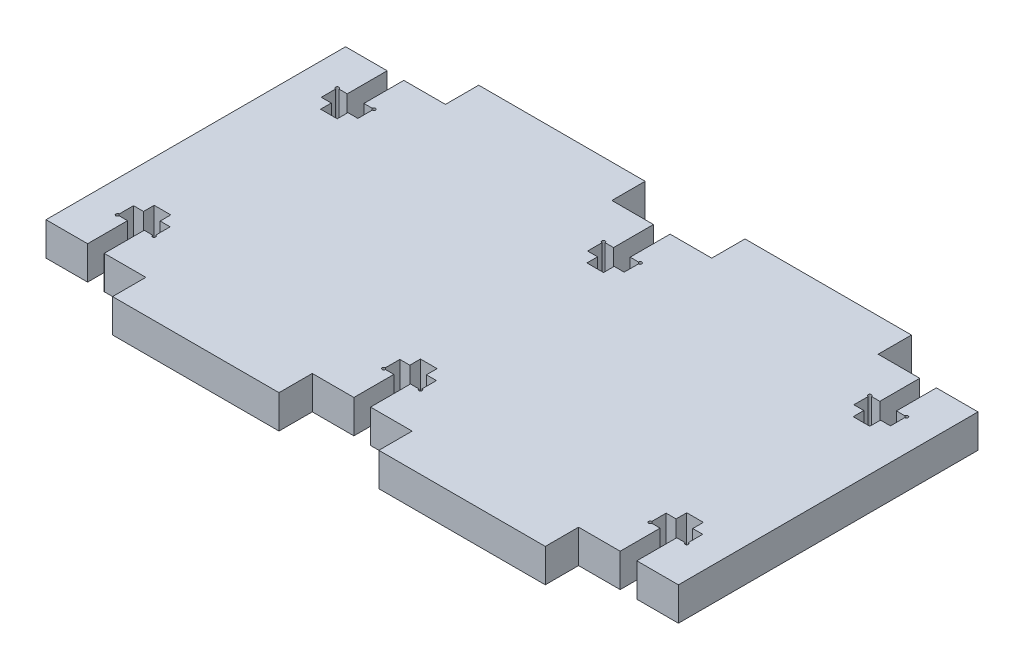
from build123d import *

# Parameters (mm, degrees)
SCHIZZO1_W                   = 95
SCHIZZO1_H                   = 55
ESTRUSIONE_ESTRUSIONE2_DEPTH = 5
SCHIZZO2_W                   = 15
SCHIZZO2_H                   = 5
TAGLIO_ESTRUSIONE1_DEPTH     = 6
TAGLIO_ESTRUSIONE3_DEPTH     = 6
SCHIZZO4_R                   = 0.25
TAGLIO_ESTRUSIONE4_DEPTH     = 10


with BuildPart() as part:
    # Schizzo1 → Estrusione-Estrusione2 (new body)
    with BuildSketch(Plane(origin=(0, 0, 0), x_dir=(1, 0, 0), z_dir=(0, 1, 0))):
        with Locations((-7.06494914, -0.781075862)):
            Rectangle(SCHIZZO1_W, SCHIZZO1_H)
    extrude(amount=-ESTRUSIONE_ESTRUSIONE2_DEPTH)

    # Schizzo2 → Taglio-Estrusione1 (cut, through all)
    with BuildSketch(Plane(origin=(0, 0, 0), x_dir=(1, 0, 0), z_dir=(0, 1, 0))):
        with Locations((-47.06494914, -25.781075862)):
            Rectangle(SCHIZZO2_W, SCHIZZO2_H)
        with Locations((-47.06494914, 24.218924138)):
            Rectangle(SCHIZZO2_W, SCHIZZO2_H)
        with Locations((32.93505086, -25.781075862)):
            Rectangle(SCHIZZO2_W, SCHIZZO2_H)
        with Locations((32.93505086, 24.218924138)):
            Rectangle(SCHIZZO2_W, SCHIZZO2_H)
        with Locations((-7.06494914, -25.781075862)):
            Rectangle(SCHIZZO2_W, SCHIZZO2_H)
        with Locations((-7.06494914, 24.218924138)):
            Rectangle(SCHIZZO2_W, SCHIZZO2_H)
    extrude(amount=-TAGLIO_ESTRUSIONE1_DEPTH, mode=Mode.SUBTRACT)

    # Schizzo3 → Taglio-Estrusione3 (cut, through all)
    with BuildSketch(Plane(origin=(0, 0, 0), x_dir=(1, 0, 0), z_dir=(0, 1, 0))):
        Polygon((-48.31494914, -23.281075862), (-45.81494914, -23.281075862), (-45.81494914, -17.281075862), (-44.31494914, -17.281075862), (-44.31494914, -14.881075862), (-45.81494914, -14.881075862), (-45.81494914, -13.281075862), (-48.31494914, -13.281075862), (-48.31494914, -14.881075862), (-49.81494914, -14.881075862), (-49.81494914, -17.281075862), (-48.31494914, -17.281075862), align=None)
        Polygon((-8.31494914, -23.281075862), (-5.81494914, -23.281075862), (-5.81494914, -17.281075862), (-4.31494914, -17.281075862), (-4.31494914, -14.881075862), (-5.81494914, -14.881075862), (-5.81494914, -13.281075862), (-8.31494914, -13.281075862), (-8.31494914, -14.881075862), (-9.81494914, -14.881075862), (-9.81494914, -17.281075862), (-8.31494914, -17.281075862), align=None)
        Polygon((31.68505086, -23.281075862), (34.18505086, -23.281075862), (34.18505086, -17.281075862), (35.68505086, -17.281075862), (35.68505086, -14.881075862), (34.18505086, -14.881075862), (34.18505086, -13.281075862), (31.68505086, -13.281075862), (31.68505086, -14.881075862), (30.18505086, -14.881075862), (30.18505086, -17.281075862), (31.68505086, -17.281075862), align=None)
        Polygon((31.68505086, 11.718924138), (34.18505086, 11.718924138), (34.18505086, 13.318924138), (35.68505086, 13.318924138), (35.68505086, 15.718924138), (34.18505086, 15.718924138), (34.18505086, 21.718924138), (31.68505086, 21.718924138), (31.68505086, 15.718924138), (30.18505086, 15.718924138), (30.18505086, 13.318924138), (31.68505086, 13.318924138), align=None)
        Polygon((-8.31494914, 11.718924138), (-5.81494914, 11.718924138), (-5.81494914, 13.318924138), (-4.31494914, 13.318924138), (-4.31494914, 15.718924138), (-5.81494914, 15.718924138), (-5.81494914, 21.718924138), (-8.31494914, 21.718924138), (-8.31494914, 15.718924138), (-9.81494914, 15.718924138), (-9.81494914, 13.318924138), (-8.31494914, 13.318924138), align=None)
        Polygon((-48.31494914, 11.718924138), (-45.81494914, 11.718924138), (-45.81494914, 13.318924138), (-44.31494914, 13.318924138), (-44.31494914, 15.718924138), (-45.81494914, 15.718924138), (-45.81494914, 21.718924138), (-48.31494914, 21.718924138), (-48.31494914, 15.718924138), (-49.81494914, 15.718924138), (-49.81494914, 13.318924138), (-48.31494914, 13.318924138), align=None)
    extrude(amount=-TAGLIO_ESTRUSIONE3_DEPTH, mode=Mode.SUBTRACT)

    # Schizzo4 → Taglio-Estrusione4 (cut)
    with BuildSketch(Plane(origin=(0, 0, 0), x_dir=(1, 0, 0), z_dir=(0, 1, 0))):
        with Locations((-49.81494914, -17.281075862)):
            Circle(SCHIZZO4_R)
        with Locations((-44.31494914, -17.281075862)):
            Circle(SCHIZZO4_R)
        with Locations((-9.81494914, -17.281075862)):
            Circle(SCHIZZO4_R)
        with Locations((-4.31494914, -17.281075862)):
            Circle(SCHIZZO4_R)
        with Locations((30.18505086, -17.281075862)):
            Circle(SCHIZZO4_R)
        with Locations((35.68505086, -17.281075862)):
            Circle(SCHIZZO4_R)
        with Locations((-49.81494914, 15.718924138)):
            Circle(SCHIZZO4_R)
        with Locations((-44.31494914, 15.718924138)):
            Circle(SCHIZZO4_R)
        with Locations((-9.81494914, 15.718924138)):
            Circle(SCHIZZO4_R)
        with Locations((-4.31494914, 15.718924138)):
            Circle(SCHIZZO4_R)
        with Locations((30.18505086, 15.718924138)):
            Circle(SCHIZZO4_R)
        with Locations((35.68505086, 15.718924138)):
            Circle(SCHIZZO4_R)
    extrude(amount=-TAGLIO_ESTRUSIONE4_DEPTH, mode=Mode.SUBTRACT)


solid = part.part
